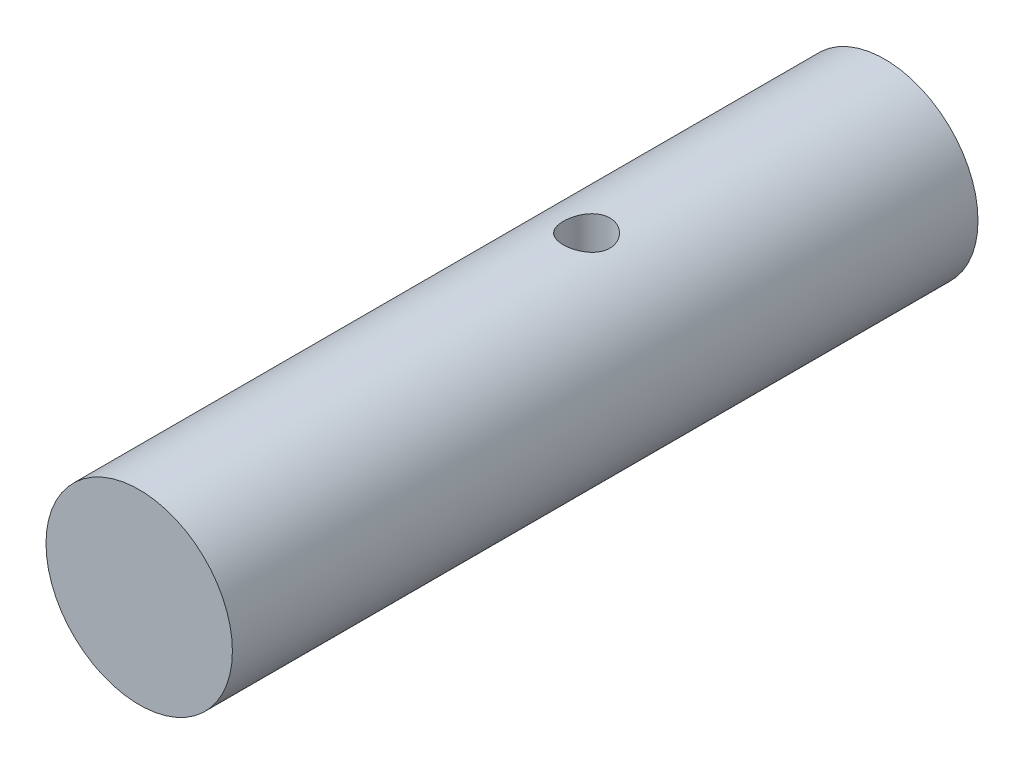
from build123d import *

# Parameters (mm, degrees)
SKETCH_2_R               = 5
EXTRUDE_1_DEPTH          = 40
SKETCH_3_R               = 1.25
CUT_EXTRUDE_1_DEPTH      = 6
CUT_EXTRUDE_1_DEPTH_BACK = 6


with BuildPart() as part:
    # ｽｹｯﾁ2 → ﾎﾞｽ - 押し出し1 (new body)
    with BuildSketch(Plane.XY):
        Circle(SKETCH_2_R)
    extrude(amount=EXTRUDE_1_DEPTH)

    # ｽｹｯﾁ3 → ｶｯﾄ - 押し出し1 (cut, two sides)
    with BuildSketch(Plane(origin=(0, 0, 0), x_dir=(1, 0, 0), z_dir=(0, 1, 0))) as cut_extrude_1_sk:
        with Locations((0, -16)):
            Circle(SKETCH_3_R)
    extrude(amount=CUT_EXTRUDE_1_DEPTH, mode=Mode.SUBTRACT)
    extrude(cut_extrude_1_sk.sketch, amount=-CUT_EXTRUDE_1_DEPTH_BACK, mode=Mode.SUBTRACT)


solid = part.part
